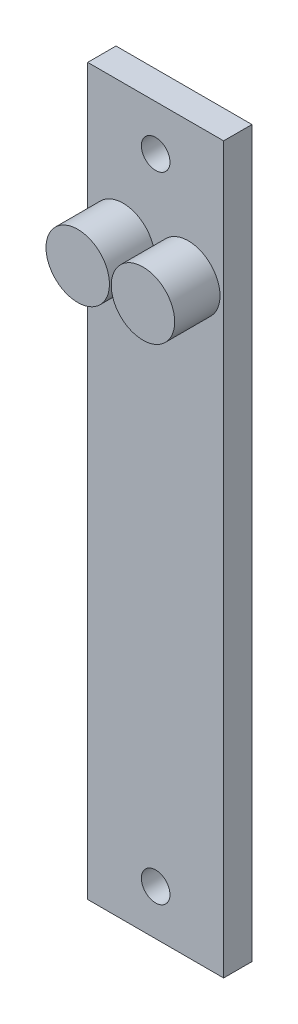
from build123d import *

# Parameters (mm, degrees)
SKETCH1_W                = 38.1
SKETCH1_H                = 203.2
BOSS_EXTRUDE1_DEPTH      = 7.9375
O_0_316_DIAMETER_HOLE1_D = 8.0264
SKETCH4_R                = 8.89
BOSS_EXTRUDE2_DEPTH      = 12.7


with BuildPart() as part:
    # Sketch1 → Boss-Extrude1 (new body)
    with BuildSketch(Plane.XY):
        Rectangle(SKETCH1_W, SKETCH1_H)
    extrude(amount=BOSS_EXTRUDE1_DEPTH)

    # O (0.316) Diameter Hole1 (through all)
    with Locations(Plane.XY.offset(7.9375)):
        with Locations((0, 88.9)):
            o_0_316_diameter_hole1 = Hole(O_0_316_DIAMETER_HOLE1_D / 2)

    # Mirror1: O (0.316) Diameter Hole1 across plane
    add(o_0_316_diameter_hole1.mirror(Plane.ZX), mode=Mode.SUBTRACT)

    # Sketch4 → Boss-Extrude2 (add)
    with BuildSketch(Plane.XY.offset(7.9375)):
        with Locations((-9.144, 63.5)):
            Circle(SKETCH4_R)
        with Locations((9.144, 63.5)):
            Circle(SKETCH4_R)
    extrude(amount=BOSS_EXTRUDE2_DEPTH)


solid = part.part
